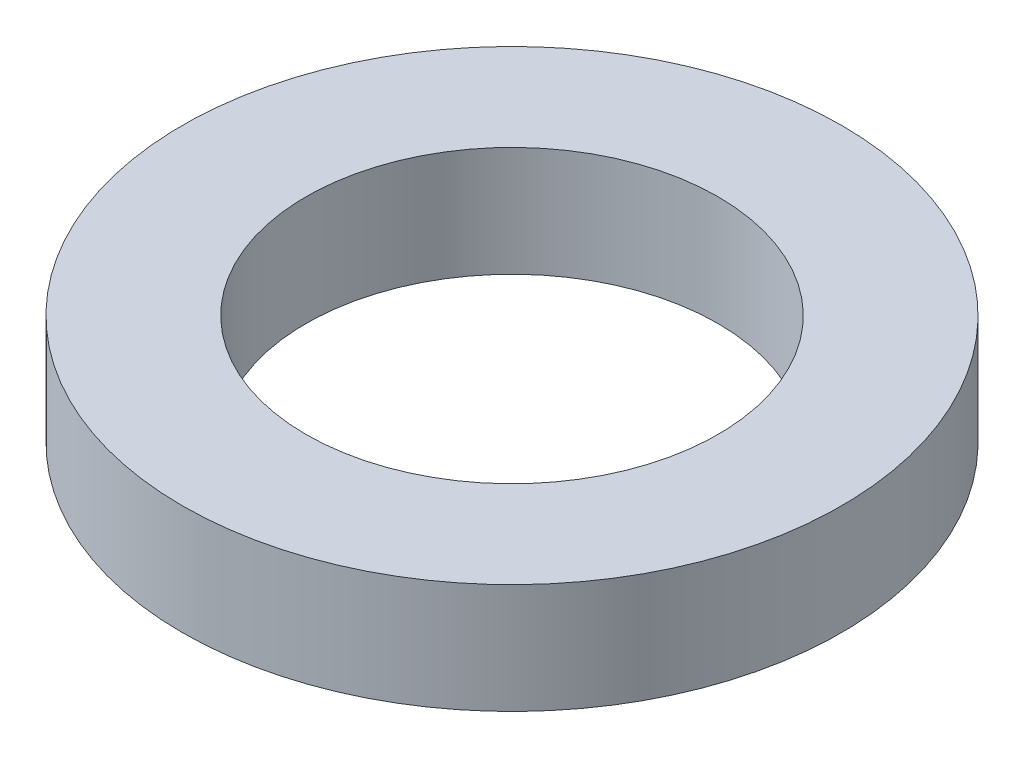
from build123d import *

# Parameters (mm, degrees)
SKETCH1_R           = 6
SKETCH1_R_2         = 3.75
BOSS_EXTRUDE1_DEPTH = 2


with BuildPart() as part:
    # Sketch1 → Boss-Extrude1 (new body)
    with BuildSketch(Plane(origin=(0, 0, 0), x_dir=(1, 0, 0), z_dir=(0, 1, 0))):
        Circle(SKETCH1_R)
        Circle(SKETCH1_R_2, mode=Mode.SUBTRACT)
    extrude(amount=BOSS_EXTRUDE1_DEPTH)


solid = part.part
